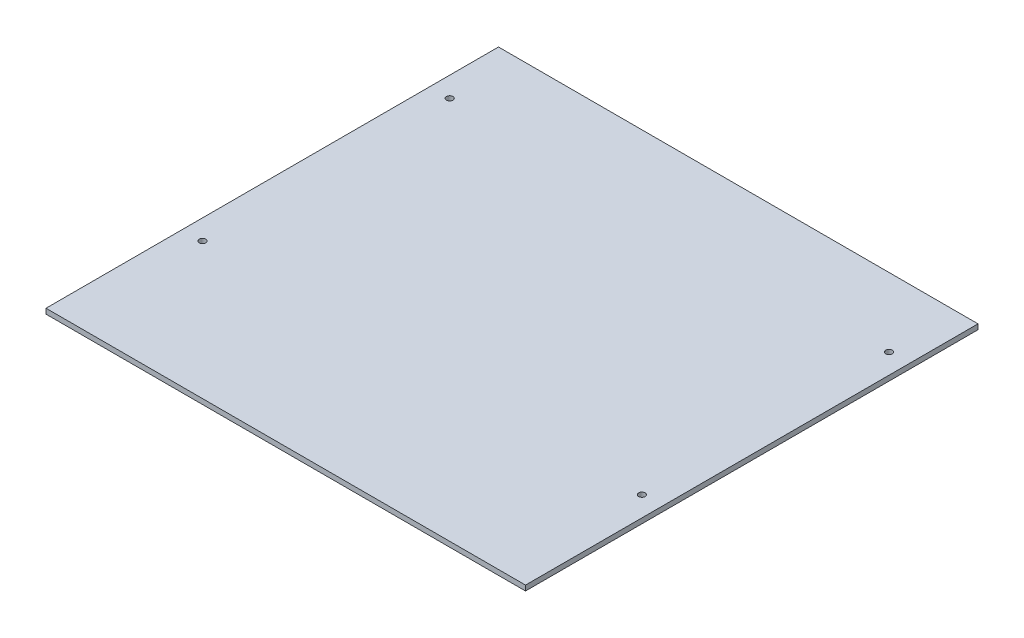
from build123d import *

# Parameters (mm, degrees)
SKETCH1_W           = 279.4
SKETCH1_H           = 263.652
SKETCH1_R           = 1.8923
BOSS_EXTRUDE1_DEPTH = 3


with BuildPart() as part:
    # Sketch1 → Boss-Extrude1 (new body)
    with BuildSketch(Plane(origin=(0, 0, 0), x_dir=(1, 0, 0), z_dir=(0, 1, 0))):
        with Locations((0, -131.826)):
            Rectangle(SKETCH1_W, SKETCH1_H)
        with Locations((-128, -40.132)):
            Circle(SKETCH1_R, mode=Mode.SUBTRACT)
        with Locations((128, -40.132)):
            Circle(SKETCH1_R, mode=Mode.SUBTRACT)
        with Locations((-128, -184.132)):
            Circle(SKETCH1_R, mode=Mode.SUBTRACT)
        with Locations((128, -184.132)):
            Circle(SKETCH1_R, mode=Mode.SUBTRACT)
    extrude(amount=BOSS_EXTRUDE1_DEPTH)


solid = part.part
